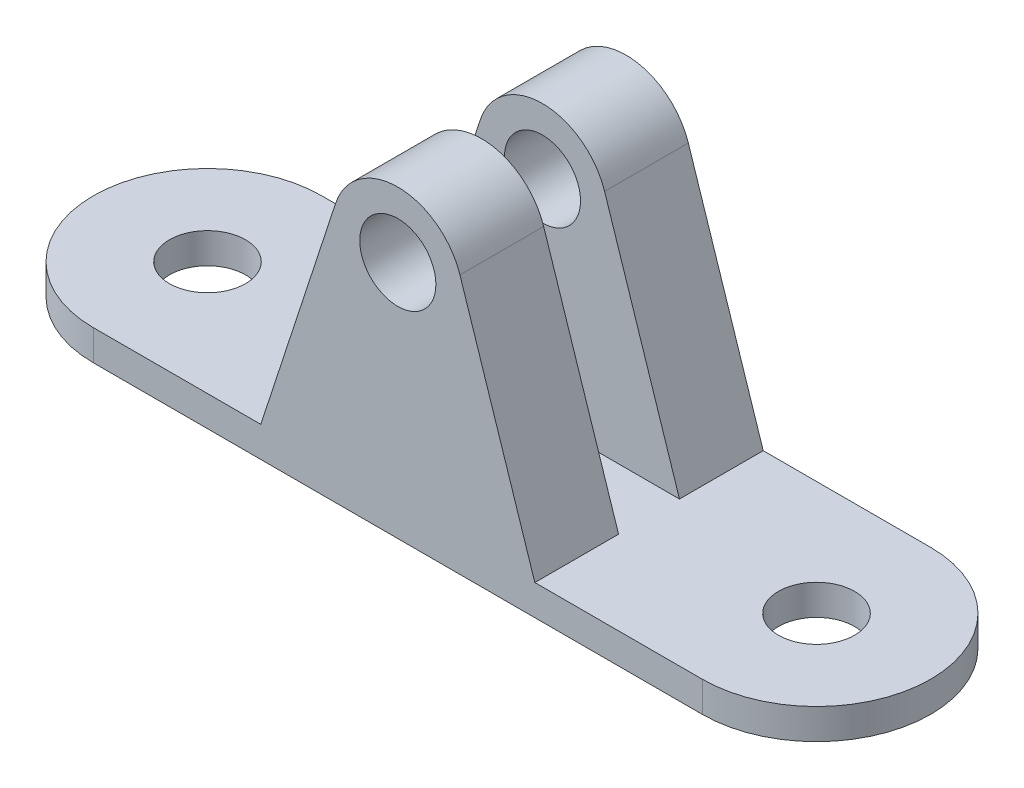
from build123d import *

# Parameters (mm, degrees)
BOSS_EXTRUDE1_DEPTH = 2
SKETCH2_R           = 2.5
BOSS_EXTRUDE2_DEPTH = 5.5
SKETCH3_R           = 2.5
CUT_EXTRUDE1_DEPTH  = 2


with BuildPart() as part:
    # Sketch1 → Boss-Extrude1 (new body)
    with BuildSketch(Plane(origin=(0, 0, 0), x_dir=(1, 0, 0), z_dir=(0, 1, 0))):
        with BuildLine():
            Line((0, 7.5), (40, 7.5))
            ThreePointArc((40, 7.5), (47.5, 0), (40, -7.5))
            Line((40, -7.5), (0, -7.5))
            ThreePointArc((0, -7.5), (-7.5, 0), (0, 7.5))
        make_face()
    extrude(amount=BOSS_EXTRUDE1_DEPTH)

    # Sketch2 → Boss-Extrude2 (add)
    with BuildSketch(Plane.XY.offset(7.5)):
        with BuildLine():
            Line((15.918750874, 17.040738272), (11, 2))
            Line((11, 2), (20, 2))
            Line((20, 2), (29, 2))
            Line((29, 2), (24.081249126, 17.040738272))
            ThreePointArc((24.081249126, 17.040738272), (20, 20), (15.918750874, 17.040738272))
        make_face()
        with Locations((20, 15.706053276)):
            Circle(SKETCH2_R, mode=Mode.SUBTRACT)
    boss_extrude2 = extrude(amount=-BOSS_EXTRUDE2_DEPTH)

    # Mirror1: Boss-Extrude2 across plane
    add(boss_extrude2.mirror(Plane.XY))

    # Sketch3 → Cut-Extrude1 (cut)
    with BuildSketch(Plane(origin=(0, 2, 0), x_dir=(1, 0, 0), z_dir=(0, 1, 0))):
        Circle(SKETCH3_R)
        with Locations((40, 0)):
            Circle(SKETCH3_R)
    extrude(amount=-CUT_EXTRUDE1_DEPTH, mode=Mode.SUBTRACT)


solid = part.part
